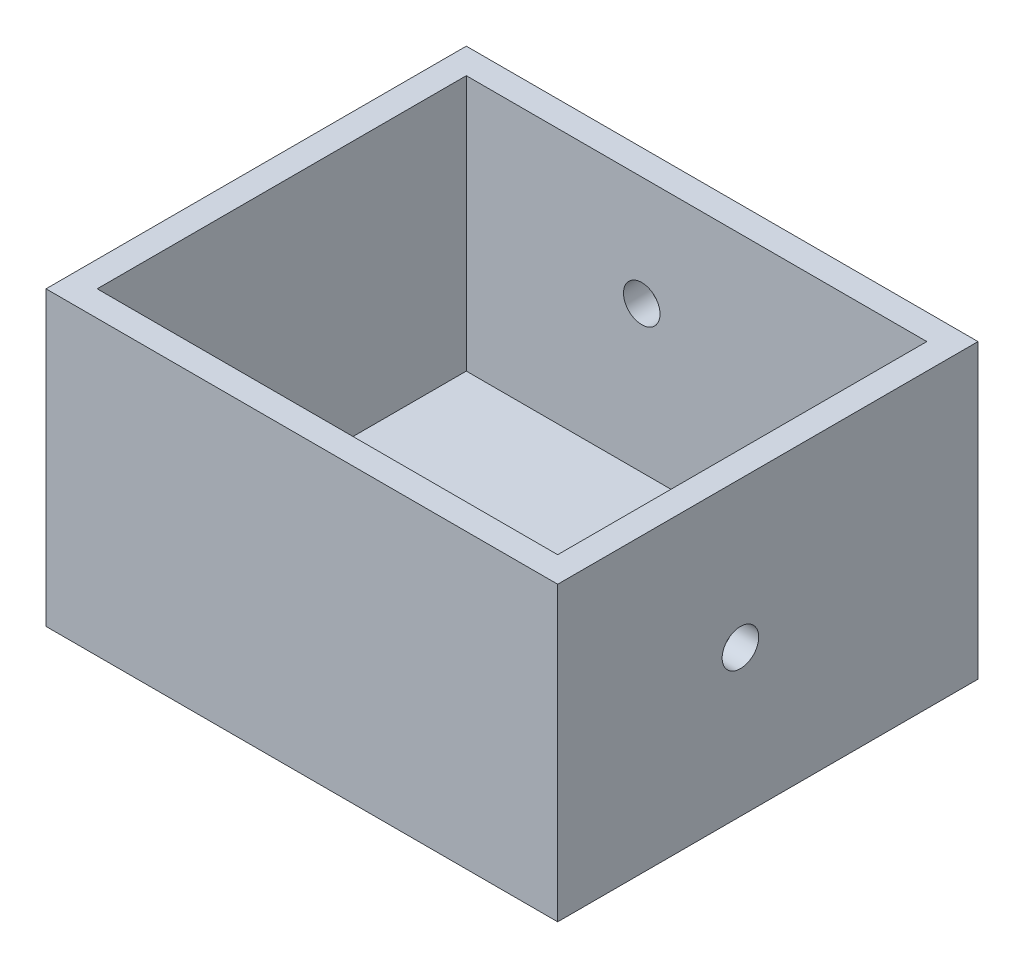
from build123d import *

# Parameters (mm, degrees)
SKETCH1_W                        = 140
SKETCH1_H                        = 115
BOSS_EXTRUDE1_DEPTH              = 80
SKETCH2_W                        = 126
SKETCH2_H                        = 101
CUT_EXTRUDE1_DEPTH               = 70
M10X1_0_TAPPED_HOLE1_D           = 9
M10X1_0_TAPPED_HOLE1_DEPTH       = 23
M10X1_0_TAPPED_HOLE1_CBORE_D     = 10
M10X1_0_TAPPED_HOLE1_CBORE_DEPTH = 20
M10X1_0_TAPPED_HOLE1_TIP         = 2.703872786
M10X1_0_TAPPED_HOLE2_D           = 9
M10X1_0_TAPPED_HOLE2_DEPTH       = 23
M10X1_0_TAPPED_HOLE2_CBORE_D     = 10
M10X1_0_TAPPED_HOLE2_CBORE_DEPTH = 20
M10X1_0_TAPPED_HOLE2_TIP         = 2.703872786


with BuildPart() as part:
    # Sketch1 → Boss-Extrude1 (new body)
    with BuildSketch(Plane(origin=(0, 0, 0), x_dir=(1, 0, 0), z_dir=(0, 1, 0))):
        with Locations((-2.716319444, -3.909068683)):
            Rectangle(SKETCH1_W, SKETCH1_H)
    extrude(amount=BOSS_EXTRUDE1_DEPTH)

    # Sketch2 → Cut-Extrude1 (cut)
    with BuildSketch(Plane(origin=(0, 80, 0), x_dir=(1, 0, 0), z_dir=(0, 1, 0))):
        with Locations((-2.716319444, -3.909068683)):
            Rectangle(SKETCH2_W, SKETCH2_H)
    extrude(amount=-CUT_EXTRUDE1_DEPTH, mode=Mode.SUBTRACT)

    # M10x1.0 Tapped Hole1
    with Locations(Plane(origin=(-17.716319444, 50, -53.590931317), x_dir=(-1, 0, 0), z_dir=(0, 0, -1))):
        with Locations((0, 0), (-60, 0)):
            CounterBoreHole(M10X1_0_TAPPED_HOLE1_D / 2, M10X1_0_TAPPED_HOLE1_CBORE_D / 2, M10X1_0_TAPPED_HOLE1_CBORE_DEPTH, depth=M10X1_0_TAPPED_HOLE1_DEPTH)
            with Locations((0, 0, -(M10X1_0_TAPPED_HOLE1_DEPTH + M10X1_0_TAPPED_HOLE1_TIP / 2))):  # 118° drill point
                Cone(0, M10X1_0_TAPPED_HOLE1_D / 2, M10X1_0_TAPPED_HOLE1_TIP, mode=Mode.SUBTRACT)

    # M10x1.0 Tapped Hole2
    with Locations(Plane(origin=(67.283680556, 40, 11.409068683), x_dir=(0, 0, 1), z_dir=(1, 0, 0))):
        with Locations((0, 0)):
            CounterBoreHole(M10X1_0_TAPPED_HOLE2_D / 2, M10X1_0_TAPPED_HOLE2_CBORE_D / 2, M10X1_0_TAPPED_HOLE2_CBORE_DEPTH, depth=M10X1_0_TAPPED_HOLE2_DEPTH)
            with Locations((0, 0, -(M10X1_0_TAPPED_HOLE2_DEPTH + M10X1_0_TAPPED_HOLE2_TIP / 2))):  # 118° drill point
                Cone(0, M10X1_0_TAPPED_HOLE2_D / 2, M10X1_0_TAPPED_HOLE2_TIP, mode=Mode.SUBTRACT)


solid = part.part
